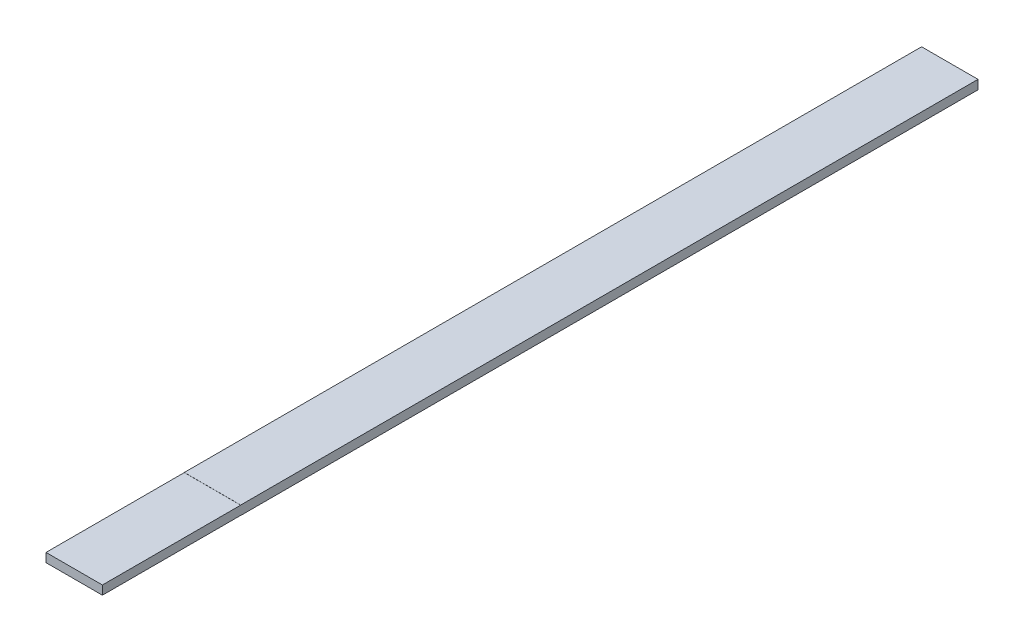
from build123d import *

# Parameters (mm, degrees)
SKETCH2_W           = 36
SKETCH2_H           = 5.8
BOSS_EXTRUDE1_DEPTH = 558.8
SKETCH3_W           = 88.25
SKETCH3_H           = 0.06858
CUT_EXTRUDE1_DEPTH  = 37


with BuildPart() as part:
    # Sketch2 → Boss-Extrude1 (new body)
    with BuildSketch(Plane.XY):
        Rectangle(SKETCH2_W, SKETCH2_H)
    extrude(amount=BOSS_EXTRUDE1_DEPTH)

    # Sketch3 → Cut-Extrude1 (cut, through all)
    with BuildSketch(Plane(origin=(18, 0, 0), x_dir=(0, 0, -1), z_dir=(1, 0, 0))):
        with Locations((-514.675, -2.86571)):
            Rectangle(SKETCH3_W, SKETCH3_H)
        with Locations((-514.675, 2.86571)):
            Rectangle(SKETCH3_W, SKETCH3_H)
    extrude(amount=-CUT_EXTRUDE1_DEPTH, mode=Mode.SUBTRACT)


solid = part.part
